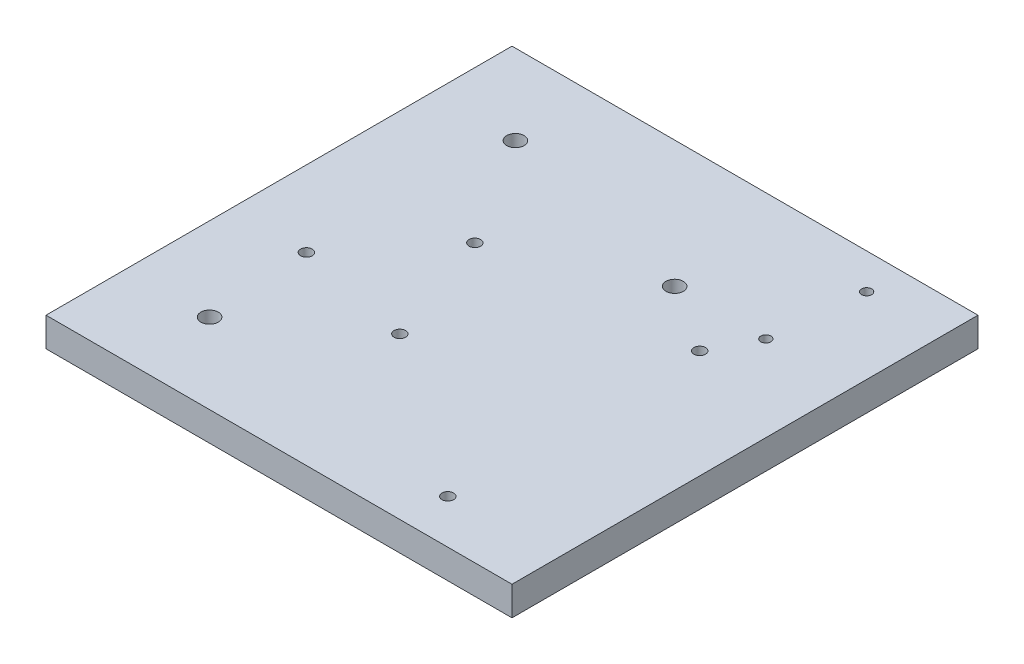
from build123d import *

# Parameters (mm, degrees)
SKETCH1_W           = 101.6
SKETCH1_H           = 101.6
BOSS_EXTRUDE1_DEPTH = 6.35
SKETCH3_R           = 1.27
CUT_EXTRUDE2_DEPTH  = 7.35
SKETCH4_R           = 1.27
CUT_EXTRUDE3_DEPTH  = 7.35
SKETCH7_R           = 1.89865
CUT_EXTRUDE5_DEPTH  = 7.35
SKETCH8_R           = 1.89865
CUT_EXTRUDE6_DEPTH  = 7.35
SKETCH10_R          = 1.1
CUT_EXTRUDE7_DEPTH  = 7.35


with BuildPart() as part:
    # Sketch1 → Boss-Extrude1 (new body)
    with BuildSketch(Plane(origin=(0, 0, 0), x_dir=(1, 0, 0), z_dir=(0, 1, 0))):
        Rectangle(SKETCH1_W, SKETCH1_H)
    extrude(amount=BOSS_EXTRUDE1_DEPTH)

    # Sketch3 → Cut-Extrude2 (cut, through all)
    with BuildSketch(Plane.XZ):
        with Locations((-8.691546024, 15.75616758)):
            Circle(SKETCH3_R)
        with Locations((-34.262562923, 10.563822948)):
            Circle(SKETCH3_R)
        with Locations((-17.714931052, -9.610745883)):
            Circle(SKETCH3_R)
    extrude(amount=-CUT_EXTRUDE2_DEPTH, mode=Mode.SUBTRACT)

    # Sketch4 → Cut-Extrude3 (cut, through all)
    with BuildSketch(Plane.XZ):
        with Locations((27.2, 41.198822948)):
            Circle(SKETCH4_R)
        with Locations((27.2, -13.721177052)):
            Circle(SKETCH4_R)
    extrude(amount=-CUT_EXTRUDE3_DEPTH, mode=Mode.SUBTRACT)

    # Sketch7 → Cut-Extrude5 (cut, through all)
    with BuildSketch(Plane.XZ):
        with Locations((-32.600738686, -33.3375)):
            Circle(SKETCH7_R)
        with Locations((-32.600738686, 33.3375)):
            Circle(SKETCH7_R)
    extrude(amount=-CUT_EXTRUDE5_DEPTH, mode=Mode.SUBTRACT)

    # Sketch8 → Cut-Extrude6 (cut, through all)
    with BuildSketch(Plane(origin=(0, 6.35, 0), x_dir=(1, 0, 0), z_dir=(0, 1, 0))):
        with Locations((12.280738686, 23.1775)):
            Circle(SKETCH8_R)
    extrude(amount=-CUT_EXTRUDE6_DEPTH, mode=Mode.SUBTRACT)

    # Sketch10 → Cut-Extrude7 (cut, through all)
    with BuildSketch(Plane(origin=(0, 6.35, 0), x_dir=(1, 0, 0), z_dir=(0, 1, 0))):
        with Locations((34.238748138, 43.081855351)):
            Circle(SKETCH10_R)
        with Locations((32.148178872, 23.191417444)):
            Circle(SKETCH10_R)
    extrude(amount=-CUT_EXTRUDE7_DEPTH, mode=Mode.SUBTRACT)


solid = part.part
